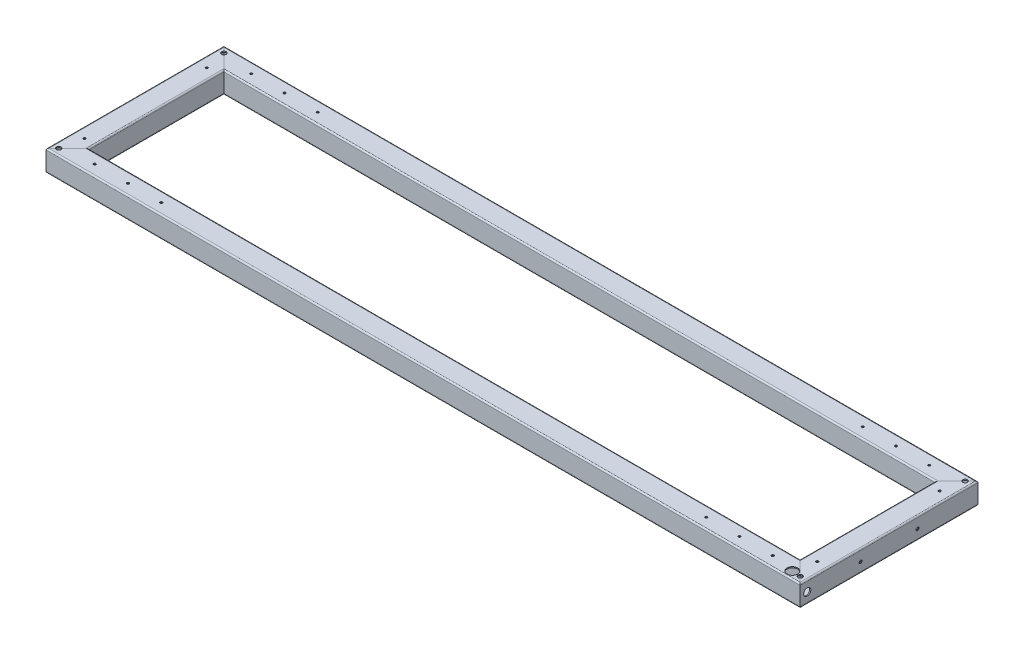
from build123d import *

# Parameters (mm, degrees)
STRUKTURBAUTEIL1_DEPTH          = 2193.426406871
STRUKTURBAUTEIL1_DEPTH_BACK     = 73.426406871
STRUKTURBAUTEIL1_2_DEPTH        = 646.852813742
STRUKTURBAUTEIL1_3_DEPTH        = 2266.852813742
STRUKTURBAUTEIL1_4_DEPTH        = 646.852813742
M6_GEWINDEBOHRUNG1_AT_2_COUNT   = 2
M6_GEWINDEBOHRUNG1_AT_2_PITCH   = 344
M6_GEWINDEBOHRUNG2_AT_2_COUNT   = 2
M6_GEWINDEBOHRUNG2_AT_2_PITCH   = 344
SCHNITT_LINEAR_AUSTRAGEN1_REACH = 1092.734
SKIZZE19_R                      = 15
SCHNITT_LINEAR_AUSTRAGEN2_REACH = 1150.085
SKIZZE20_R                      = 15
SCHNITT_LINEAR_AUSTRAGEN3_REACH = 2136.9
SKIZZE21_R                      = 10
SCHNITT_LINEAR_AUSTRAGEN4_REACH = 1092.734
SKIZZE22_R                      = 15
SCHNITT_LINEAR_AUSTRAGEN5_REACH = 2136.9
SKIZZE23_R                      = 10
M8_GEWINDEBOHRUNG1_AT_2_COUNT   = 2
M8_GEWINDEBOHRUNG1_AT_2_PITCH   = 160
SKIZZE26_R                      = 6.5
SCHNITT_LINEAR_AUSTRAGEN6_DEPTH = 1091.733698022
M6_GEWINDEBOHRUNG3_AT_2_COUNT   = 2
M6_GEWINDEBOHRUNG3_AT_2_PITCH   = 93.5
M6_GEWINDEBOHRUNG3_AT_3_COUNT   = 2
M6_GEWINDEBOHRUNG3_AT_3_PITCH   = 187
M6_GEWINDEBOHRUNG3_AT_4_COUNT   = 2
M6_GEWINDEBOHRUNG3_AT_4_PITCH   = 1719
M6_GEWINDEBOHRUNG3_AT_5_COUNT   = 2
M6_GEWINDEBOHRUNG3_AT_5_PITCH   = 1812.5
M6_GEWINDEBOHRUNG3_AT_6_COUNT   = 2
M6_GEWINDEBOHRUNG3_AT_6_PITCH   = 1906
M6_GEWINDEBOHRUNG3_AT_7_COUNT   = 2
M6_GEWINDEBOHRUNG3_AT_7_PITCH   = 1774.418496297
M6_GEWINDEBOHRUNG3_AT_8_COUNT   = 2
M6_GEWINDEBOHRUNG3_AT_8_PITCH   = 1865.142420835
M6_GEWINDEBOHRUNG3_AT_9_COUNT   = 2
M6_GEWINDEBOHRUNG3_AT_9_PITCH   = 1956.127807685
M6_GEWINDEBOHRUNG3_AT_10_COUNT  = 2
M6_GEWINDEBOHRUNG3_AT_10_PITCH  = 440
M6_GEWINDEBOHRUNG3_AT_11_COUNT  = 2
M6_GEWINDEBOHRUNG3_AT_11_PITCH  = 449.824688073
M6_GEWINDEBOHRUNG3_AT_12_COUNT  = 2
M6_GEWINDEBOHRUNG3_AT_12_PITCH  = 478.088903866


with BuildPart() as part:
    # Skizze12 → Strukturbauteil1 (new, two sides)
    with BuildSketch(Plane(origin=(-1060, 0, -220), x_dir=(0, 0, -1), z_dir=(1, 0, 0))) as strukturbauteil1_sk:
        with BuildLine():
            Line((26, -30), (-26, -30))
            ThreePointArc((-26, -30), (-28.828427125, -28.828427125), (-30, -26))
            Line((-30, -26), (-30, 26))
            ThreePointArc((-30, 26), (-28.828427125, 28.828427125), (-26, 30))
            Line((-26, 30), (26, 30))
            ThreePointArc((26, 30), (28.828427125, 28.828427125), (30, 26))
            Line((30, 26), (30, -26))
            ThreePointArc((30, -26), (28.828427125, -28.828427125), (26, -30))
        make_face()
        with BuildLine():
            Line((27, -26), (27, 26))
            ThreePointArc((27, 26), (26.707106781, 26.707106781), (26, 27))
            Line((26, 27), (-26, 27))
            ThreePointArc((-26, 27), (-26.707106781, 26.707106781), (-27, 26))
            Line((-27, 26), (-27, -26))
            ThreePointArc((-27, -26), (-26.707106781, -26.707106781), (-26, -27))
            Line((-26, -27), (26, -27))
            ThreePointArc((26, -27), (26.707106781, -26.707106781), (27, -26))
        make_face(mode=Mode.SUBTRACT)
    extrude(amount=STRUKTURBAUTEIL1_DEPTH)
    extrude(strukturbauteil1_sk.sketch, amount=-STRUKTURBAUTEIL1_DEPTH_BACK)

    # Strukturbauteil1 mitre 1
    split(bisect_by=Plane(origin=(-1060, 0, -250), x_dir=(0, 1, 0), z_dir=(0.707106781, 0, -0.707106781)), keep=Keep.TOP)

    # Strukturbauteil1 mitre 2
    split(bisect_by=Plane(origin=(1060, 0, -250), x_dir=(0, -1, 0), z_dir=(-0.707106781, 0, -0.707106781)), keep=Keep.TOP)


with BuildPart() as body_2:
    # Skizze12 on segment 2 (carried to segment 2) → Strukturbauteil1 2 (new body)
    with BuildSketch(Plane(origin=(1030, 0, -323.426406871), x_dir=(1, 0, 0), z_dir=(0, 0, 1))):
        with BuildLine():
            Line((26, -30), (-26, -30))
            ThreePointArc((-26, -30), (-28.828427125, -28.828427125), (-30, -26))
            Line((-30, -26), (-30, 26))
            ThreePointArc((-30, 26), (-28.828427125, 28.828427125), (-26, 30))
            Line((-26, 30), (26, 30))
            ThreePointArc((26, 30), (28.828427125, 28.828427125), (30, 26))
            Line((30, 26), (30, -26))
            ThreePointArc((30, -26), (28.828427125, -28.828427125), (26, -30))
        make_face()
        with BuildLine():
            Line((27, -26), (27, 26))
            ThreePointArc((27, 26), (26.707106781, 26.707106781), (26, 27))
            Line((26, 27), (-26, 27))
            ThreePointArc((-26, 27), (-26.707106781, 26.707106781), (-27, 26))
            Line((-27, 26), (-27, -26))
            ThreePointArc((-27, -26), (-26.707106781, -26.707106781), (-26, -27))
            Line((-26, -27), (26, -27))
            ThreePointArc((26, -27), (26.707106781, -26.707106781), (27, -26))
        make_face(mode=Mode.SUBTRACT)
    extrude(amount=STRUKTURBAUTEIL1_2_DEPTH)

    # Strukturbauteil1 2 mitre 1
    split(bisect_by=Plane(origin=(1060, 0, -250), x_dir=(0, 1, 0), z_dir=(0.707106781, 0, 0.707106781)), keep=Keep.TOP)

    # Strukturbauteil1 2 mitre 2
    split(bisect_by=Plane(origin=(1060, 0, 250), x_dir=(0, 1, 0), z_dir=(0.707106781, 0, -0.707106781)), keep=Keep.TOP)


with BuildPart() as body_3:
    # Skizze12 on segment 3 (carried to segment 3) → Strukturbauteil1 3 (new body)
    with BuildSketch(Plane(origin=(1133.426406871, 0, 220), x_dir=(0, 0, 1), z_dir=(-1, 0, 0))):
        with BuildLine():
            Line((26, -30), (-26, -30))
            ThreePointArc((-26, -30), (-28.828427125, -28.828427125), (-30, -26))
            Line((-30, -26), (-30, 26))
            ThreePointArc((-30, 26), (-28.828427125, 28.828427125), (-26, 30))
            Line((-26, 30), (26, 30))
            ThreePointArc((26, 30), (28.828427125, 28.828427125), (30, 26))
            Line((30, 26), (30, -26))
            ThreePointArc((30, -26), (28.828427125, -28.828427125), (26, -30))
        make_face()
        with BuildLine():
            Line((27, -26), (27, 26))
            ThreePointArc((27, 26), (26.707106781, 26.707106781), (26, 27))
            Line((26, 27), (-26, 27))
            ThreePointArc((-26, 27), (-26.707106781, 26.707106781), (-27, 26))
            Line((-27, 26), (-27, -26))
            ThreePointArc((-27, -26), (-26.707106781, -26.707106781), (-26, -27))
            Line((-26, -27), (26, -27))
            ThreePointArc((26, -27), (26.707106781, -26.707106781), (27, -26))
        make_face(mode=Mode.SUBTRACT)
    extrude(amount=STRUKTURBAUTEIL1_3_DEPTH)

    # Strukturbauteil1 3 mitre 1
    split(bisect_by=Plane(origin=(-1060, 0, 250), x_dir=(0, 1, 0), z_dir=(0.707106781, 0, 0.707106781)), keep=Keep.TOP)

    # Strukturbauteil1 3 mitre 2
    split(bisect_by=Plane(origin=(1060, 0, 250), x_dir=(0, -1, 0), z_dir=(-0.707106781, 0, 0.707106781)), keep=Keep.TOP)


with BuildPart() as body_4:
    # Skizze12 on segment 4 (carried to segment 4) → Strukturbauteil1 4 (new body)
    with BuildSketch(Plane(origin=(-1030, 0, 323.426406871), x_dir=(-1, 0, 0), z_dir=(0, 0, -1))):
        with BuildLine():
            Line((26, -30), (-26, -30))
            ThreePointArc((-26, -30), (-28.828427125, -28.828427125), (-30, -26))
            Line((-30, -26), (-30, 26))
            ThreePointArc((-30, 26), (-28.828427125, 28.828427125), (-26, 30))
            Line((-26, 30), (26, 30))
            ThreePointArc((26, 30), (28.828427125, 28.828427125), (30, 26))
            Line((30, 26), (30, -26))
            ThreePointArc((30, -26), (28.828427125, -28.828427125), (26, -30))
        make_face()
        with BuildLine():
            Line((27, -26), (27, 26))
            ThreePointArc((27, 26), (26.707106781, 26.707106781), (26, 27))
            Line((26, 27), (-26, 27))
            ThreePointArc((-26, 27), (-26.707106781, 26.707106781), (-27, 26))
            Line((-27, 26), (-27, -26))
            ThreePointArc((-27, -26), (-26.707106781, -26.707106781), (-26, -27))
            Line((-26, -27), (26, -27))
            ThreePointArc((26, -27), (26.707106781, -26.707106781), (27, -26))
        make_face(mode=Mode.SUBTRACT)
    extrude(amount=STRUKTURBAUTEIL1_4_DEPTH)

    # Strukturbauteil1 4 mitre 1
    split(bisect_by=Plane(origin=(-1060, 0, -250), x_dir=(0, -1, 0), z_dir=(-0.707106781, 0, 0.707106781)), keep=Keep.TOP)

    # Strukturbauteil1 4 mitre 2
    split(bisect_by=Plane(origin=(-1060, 0, 250), x_dir=(0, -1, 0), z_dir=(-0.707106781, 0, -0.707106781)), keep=Keep.TOP)


with BuildPart() as part_1:
    add(part.part)

    # Strukturbauteil1 as one body: union body 2, body 3, body 4
    add(body_2.part)
    add(body_3.part)
    add(body_4.part)

    # Skizze15 → M6 Gewindebohrung1 (revolve, cut)
    with BuildSketch(Plane(origin=(1030, 30, 172), x_dir=(0, 0, 1), z_dir=(1, 0, 0))):
        Polygon((0, 0), (0, 3), (3.025, 3), (2.5, 2.475), (2.5, 0.75), (3.25, 0), align=None)
    m6_gewindebohrung1 = revolve(axis=Axis((1030, 36.35, 172), (0, -1, 0)), mode=Mode.SUBTRACT)

    # M6 Gewindebohrung1 at 2: M6 Gewindebohrung1 ×2
    with Locations(*[(0, 0, -i * M6_GEWINDEBOHRUNG1_AT_2_PITCH) for i in range(1, M6_GEWINDEBOHRUNG1_AT_2_COUNT)]):
        add(m6_gewindebohrung1, mode=Mode.SUBTRACT)

    # Skizze17 → M6 Gewindebohrung2 (revolve, cut)
    with BuildSketch(Plane(origin=(-1030, 30, -172), x_dir=(0, 0, 1), z_dir=(1, 0, 0))):
        Polygon((0, 0), (0, 3), (3.025, 3), (2.5, 2.475), (2.5, 0.75), (3.25, 0), align=None)
    m6_gewindebohrung2 = revolve(axis=Axis((-1030, 36.35, -172), (0, -1, 0)), mode=Mode.SUBTRACT)

    # M6 Gewindebohrung2 at 2: M6 Gewindebohrung2 ×2
    with Locations(*[(0, 0, i * M6_GEWINDEBOHRUNG2_AT_2_PITCH) for i in range(1, M6_GEWINDEBOHRUNG2_AT_2_COUNT)]):
        add(m6_gewindebohrung2, mode=Mode.SUBTRACT)

    # Skizze19 → Schnitt-Linear austragen1 (cut, up to next)
    with BuildSketch(Plane(origin=(0, 30, 0), x_dir=(1, 0, 0), z_dir=(0, 1, 0)), mode=Mode.PRIVATE) as schnitt_linear_austragen1_sk1:
        with Locations(Location((1018, -230, 0), (0, 0, 270))):
            Circle(SKIZZE19_R)
    schnitt_linear_austragen1_tool1 = extrude(schnitt_linear_austragen1_sk1.sketch, amount=-SCHNITT_LINEAR_AUSTRAGEN1_REACH, mode=Mode.PRIVATE) & part_1.part
    add(schnitt_linear_austragen1_tool1.solids().sort_by_distance((1018, 30, 230))[0], mode=Mode.SUBTRACT)

    # Skizze20 → Schnitt-Linear austragen2 (cut, up to next)
    with BuildSketch(Plane(origin=(0, 0, 190), x_dir=(-1, 0, 0), z_dir=(0, 0, -1)), mode=Mode.PRIVATE) as schnitt_linear_austragen2_sk1:
        with Locations((-670, 0)):
            Circle(SKIZZE20_R)
    schnitt_linear_austragen2_tool1 = extrude(schnitt_linear_austragen2_sk1.sketch, amount=-SCHNITT_LINEAR_AUSTRAGEN2_REACH, mode=Mode.PRIVATE) & part_1.part
    add(schnitt_linear_austragen2_tool1.solids().sort_by_distance((670, 0, 190))[0], mode=Mode.SUBTRACT)

    # Skizze21 → Schnitt-Linear austragen3 (cut, up to next)
    with BuildSketch(Plane(origin=(1060, 0, 0), x_dir=(0, 0, -1), z_dir=(1, 0, 0)), mode=Mode.PRIVATE) as schnitt_linear_austragen3_sk1:
        with Locations(Location((-230, 0, 0), (0, 0, 90))):
            Circle(SKIZZE21_R)
    schnitt_linear_austragen3_tool1 = extrude(schnitt_linear_austragen3_sk1.sketch, amount=-SCHNITT_LINEAR_AUSTRAGEN3_REACH, mode=Mode.PRIVATE) & part_1.part
    add(schnitt_linear_austragen3_tool1.solids().sort_by_distance((1060, 0, 230))[0], mode=Mode.SUBTRACT)

    # Skizze22 → Schnitt-Linear austragen4 (cut, up to next)
    with BuildSketch(Plane.XZ.offset(30), mode=Mode.PRIVATE) as schnitt_linear_austragen4_sk1:
        with Locations((-1030, 0)):
            Circle(SKIZZE22_R)
    schnitt_linear_austragen4_tool1 = extrude(schnitt_linear_austragen4_sk1.sketch, amount=-SCHNITT_LINEAR_AUSTRAGEN4_REACH, mode=Mode.PRIVATE) & part_1.part
    # Skizze22 → Schnitt-Linear austragen4 (cut, up to next)
    with BuildSketch(Plane.XZ.offset(30), mode=Mode.PRIVATE) as schnitt_linear_austragen4_sk2:
        with Locations((1030, 0)):
            Circle(SKIZZE22_R)
    schnitt_linear_austragen4_tool2 = extrude(schnitt_linear_austragen4_sk2.sketch, amount=-SCHNITT_LINEAR_AUSTRAGEN4_REACH, mode=Mode.PRIVATE) & part_1.part
    add(schnitt_linear_austragen4_tool1.solids().sort_by_distance((-1030, -30, 0))[0], mode=Mode.SUBTRACT)
    add(schnitt_linear_austragen4_tool2.solids().sort_by_distance((1030, -30, 0))[0], mode=Mode.SUBTRACT)

    # Skizze23 → Schnitt-Linear austragen5 (cut, up to next)
    with BuildSketch(Plane.ZY.offset(1060), mode=Mode.PRIVATE) as schnitt_linear_austragen5_sk1:
        with Locations(Location((230, 0, 0), (0, 0, 90))):
            Circle(SKIZZE23_R)
    schnitt_linear_austragen5_tool1 = extrude(schnitt_linear_austragen5_sk1.sketch, amount=-SCHNITT_LINEAR_AUSTRAGEN5_REACH, mode=Mode.PRIVATE) & part_1.part
    add(schnitt_linear_austragen5_tool1.solids().sort_by_distance((-1060, 0, 230))[0], mode=Mode.SUBTRACT)

    # Skizze24 → M8 Gewindebohrung1 (revolve, cut)
    with BuildSketch(Plane(origin=(1060, -1.497451675, 80), x_dir=(0, 0, -1), z_dir=(0, 1, 0))):
        Polygon((0, 0), (0, 3), (3.4, 3), (3.4, 0.85), (4.25, 0), align=None)
    m8_gewindebohrung1 = revolve(axis=Axis((1066.35, -1.497451675, 80), (-1, 0, 0)), mode=Mode.SUBTRACT)

    # M8 Gewindebohrung1 at 2: M8 Gewindebohrung1 ×2
    with Locations(*[(0, 0, -i * M8_GEWINDEBOHRUNG1_AT_2_PITCH) for i in range(1, M8_GEWINDEBOHRUNG1_AT_2_COUNT)]):
        add(m8_gewindebohrung1, mode=Mode.SUBTRACT)

    # Skizze26 → Schnitt-Linear austragen6 (cut, through all)
    with BuildSketch(Plane(origin=(0, 30, 0), x_dir=(1, 0, 0), z_dir=(0, 1, 0))):
        with Locations(Location((-1042, -232, 0), (0, 0, 225))):
            Circle(SKIZZE26_R)
        with Locations(Location((-1042, 232, 0), (0, 0, 315))):
            Circle(SKIZZE26_R)
        with Locations(Location((1042, 232, 0), (0, 0, 225))):
            Circle(SKIZZE26_R)
        with Locations(Location((1042, -232, 0), (0, 0, 315))):
            Circle(SKIZZE26_R)
    extrude(amount=-SCHNITT_LINEAR_AUSTRAGEN6_DEPTH, mode=Mode.SUBTRACT)

    # Skizze41 → M6 Gewindebohrung3 (revolve, cut)
    with BuildSketch(Plane(origin=(-953, 30, -220), x_dir=(0, 0, 1), z_dir=(1, 0, 0))):
        Polygon((0, 0), (0, 3), (2.5, 3), (2.5, 0.75), (3.25, 0), align=None)
    m6_gewindebohrung3 = revolve(axis=Axis((-953, 36.35, -220), (0, -1, 0)), mode=Mode.SUBTRACT)

    # M6 Gewindebohrung3 at 2: M6 Gewindebohrung3 ×2
    with Locations(*[(i * M6_GEWINDEBOHRUNG3_AT_2_PITCH, 0, 0) for i in range(1, M6_GEWINDEBOHRUNG3_AT_2_COUNT)]):
        add(m6_gewindebohrung3, mode=Mode.SUBTRACT)

    # M6 Gewindebohrung3 at 3: M6 Gewindebohrung3 ×2
    with Locations(*[(i * M6_GEWINDEBOHRUNG3_AT_3_PITCH, 0, 0) for i in range(1, M6_GEWINDEBOHRUNG3_AT_3_COUNT)]):
        add(m6_gewindebohrung3, mode=Mode.SUBTRACT)

    # M6 Gewindebohrung3 at 4: M6 Gewindebohrung3 ×2
    with Locations(*[(i * M6_GEWINDEBOHRUNG3_AT_4_PITCH, 0, 0) for i in range(1, M6_GEWINDEBOHRUNG3_AT_4_COUNT)]):
        add(m6_gewindebohrung3, mode=Mode.SUBTRACT)

    # M6 Gewindebohrung3 at 5: M6 Gewindebohrung3 ×2
    with Locations(*[(i * M6_GEWINDEBOHRUNG3_AT_5_PITCH, 0, 0) for i in range(1, M6_GEWINDEBOHRUNG3_AT_5_COUNT)]):
        add(m6_gewindebohrung3, mode=Mode.SUBTRACT)

    # M6 Gewindebohrung3 at 6: M6 Gewindebohrung3 ×2
    with Locations(*[(i * M6_GEWINDEBOHRUNG3_AT_6_PITCH, 0, 0) for i in range(1, M6_GEWINDEBOHRUNG3_AT_6_COUNT)]):
        add(m6_gewindebohrung3, mode=Mode.SUBTRACT)

    # M6 Gewindebohrung3 at 7: M6 Gewindebohrung3 ×2
    with Locations(*[Vector(0.9687680801274315, 0, 0.24796856035838577) * (i * M6_GEWINDEBOHRUNG3_AT_7_PITCH) for i in range(1, M6_GEWINDEBOHRUNG3_AT_7_COUNT)]):
        add(m6_gewindebohrung3, mode=Mode.SUBTRACT)

    # M6 Gewindebohrung3 at 8: M6 Gewindebohrung3 ×2
    with Locations(*[Vector(0.9717756562461923, 0, 0.2359069179301073) * (i * M6_GEWINDEBOHRUNG3_AT_8_PITCH) for i in range(1, M6_GEWINDEBOHRUNG3_AT_8_COUNT)]):
        add(m6_gewindebohrung3, mode=Mode.SUBTRACT)

    # M6 Gewindebohrung3 at 9: M6 Gewindebohrung3 ×2
    with Locations(*[Vector(0.9743739608994719, 0, 0.22493417775223615) * (i * M6_GEWINDEBOHRUNG3_AT_9_PITCH) for i in range(1, M6_GEWINDEBOHRUNG3_AT_9_COUNT)]):
        add(m6_gewindebohrung3, mode=Mode.SUBTRACT)

    # M6 Gewindebohrung3 at 10: M6 Gewindebohrung3 ×2
    with Locations(*[(0, 0, i * M6_GEWINDEBOHRUNG3_AT_10_PITCH) for i in range(1, M6_GEWINDEBOHRUNG3_AT_10_COUNT)]):
        add(m6_gewindebohrung3, mode=Mode.SUBTRACT)

    # M6 Gewindebohrung3 at 11: M6 Gewindebohrung3 ×2
    with Locations(*[Vector(0.20785875582005006, 0, 0.9781588509178563) * (i * M6_GEWINDEBOHRUNG3_AT_11_PITCH) for i in range(1, M6_GEWINDEBOHRUNG3_AT_11_COUNT)]):
        add(m6_gewindebohrung3, mode=Mode.SUBTRACT)

    # M6 Gewindebohrung3 at 12: M6 Gewindebohrung3 ×2
    with Locations(*[Vector(0.39114064034486057, 0, 0.9203309184584708) * (i * M6_GEWINDEBOHRUNG3_AT_12_PITCH) for i in range(1, M6_GEWINDEBOHRUNG3_AT_12_COUNT)]):
        add(m6_gewindebohrung3, mode=Mode.SUBTRACT)


solid = part_1.part
